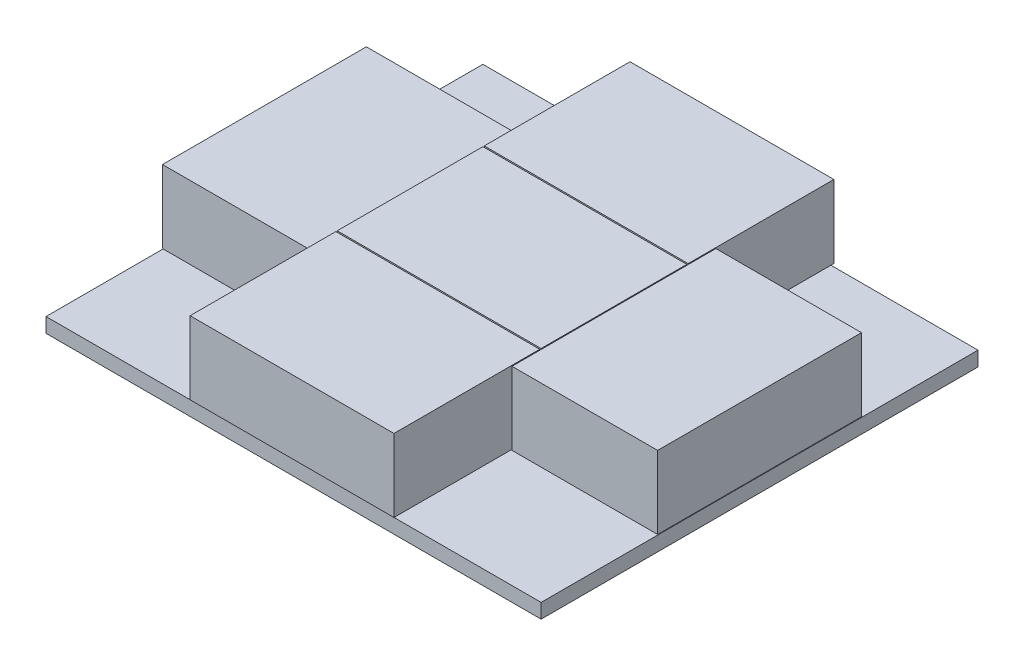
from build123d import *

# Parameters (mm, degrees)
SKETCH1_W           = 170
SKETCH1_H           = 150
BOSS_EXTRUDE1_DEPTH = 5
SKETCH4_W           = 65
SKETCH4_H           = 45
BOSS_EXTRUDE2_DEPTH = 0.5
SKETCH5_W           = 70
SKETCH5_H           = 50.044144688
BOSS_EXTRUDE3_DEPTH = 25
LPATTERN3_COUNT     = 2
LPATTERN3_PITCH     = 50.5
LPATTERN3_COL_COUNT = 2
LPATTERN3_COL_PITCH = 50.5
SKETCH6_W           = 45
SKETCH6_H           = 65
BOSS_EXTRUDE4_DEPTH = 0.2
SKETCH7_W           = 50
SKETCH7_H           = 70
BOSS_EXTRUDE5_DEPTH = 25
LPATTERN4_COUNT     = 2
LPATTERN4_PITCH     = 120


with BuildPart() as part:
    # Sketch1 → Boss-Extrude1 (new body)
    with BuildSketch(Plane(origin=(0, 0, 0), x_dir=(1, 0, 0), z_dir=(0, 1, 0))):
        Rectangle(SKETCH1_W, SKETCH1_H)
    extrude(amount=BOSS_EXTRUDE1_DEPTH)

    # Sketch4 → Boss-Extrude2 (add)
    with BuildSketch(Plane(origin=(0, 5, 0), x_dir=(1, 0, 0), z_dir=(0, 1, 0))):
        Rectangle(SKETCH4_W, SKETCH4_H)
    boss_extrude2 = extrude(amount=BOSS_EXTRUDE2_DEPTH)

    # Sketch5 → Boss-Extrude3 (add)
    with BuildSketch(Plane(origin=(0, 5.5, 0), x_dir=(1, 0, 0), z_dir=(0, 1, 0))):
        Rectangle(SKETCH5_W, SKETCH5_H)
    boss_extrude3 = extrude(amount=BOSS_EXTRUDE3_DEPTH)

    # LPattern3: Boss-Extrude2, Boss-Extrude3 ×2
    with Locations(*[(0, 0, i * LPATTERN3_PITCH) for i in range(1, LPATTERN3_COUNT)]):
        add(boss_extrude2)
        add(boss_extrude3)

    # LPattern3 col: Boss-Extrude2, Boss-Extrude3 ×2
    with Locations(*[(0, 0, -i * LPATTERN3_COL_PITCH) for i in range(1, LPATTERN3_COL_COUNT)]):
        add(boss_extrude2)
        add(boss_extrude3)

    # Sketch6 → Boss-Extrude4 (add)
    with BuildSketch(Plane(origin=(0, 5, 0), x_dir=(1, 0, 0), z_dir=(0, 1, 0))):
        with Locations((60, 0)):
            Rectangle(SKETCH6_W, SKETCH6_H)
    boss_extrude4 = extrude(amount=BOSS_EXTRUDE4_DEPTH)

    # Sketch7 → Boss-Extrude5 (add)
    with BuildSketch(Plane(origin=(0, 5.2, 0), x_dir=(1, 0, 0), z_dir=(0, 1, 0))):
        with Locations((60, 0)):
            Rectangle(SKETCH7_W, SKETCH7_H)
    boss_extrude5 = extrude(amount=BOSS_EXTRUDE5_DEPTH)

    # LPattern4: Boss-Extrude4, Boss-Extrude5 ×2
    with Locations(*[(-i * LPATTERN4_PITCH, 0, 0) for i in range(1, LPATTERN4_COUNT)]):
        add(boss_extrude4)
        add(boss_extrude5)


solid = part.part
